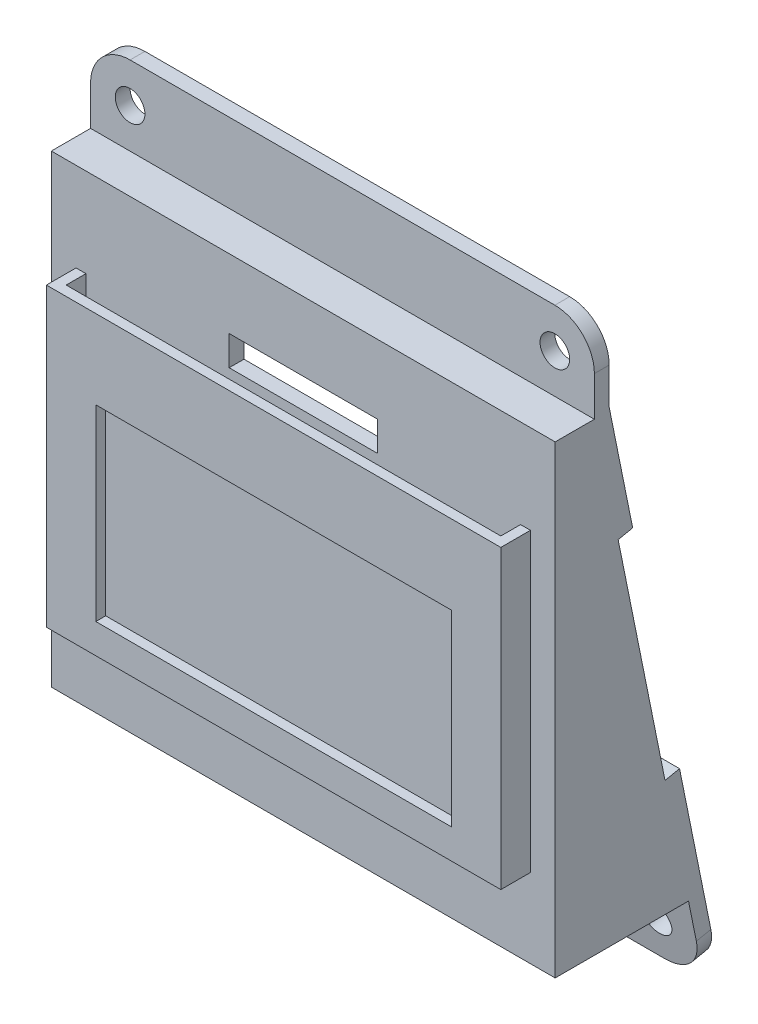
from build123d import *

# Parameters (mm, degrees)
SKETCH_1_W          = 51
SKETCH_1_H          = 47
SKETCH_1_W_2        = 15
SKETCH_1_H_2        = 3
EXTRUDE_1_DEPTH     = 1.5
EXTRUDE_2_DEPTH     = 2
SKETCH_3_W          = 46
SKETCH_3_H          = 30
SKETCH_3_W_2        = 36
SKETCH_3_H_2        = 19
EXTRUDE_3_DEPTH     = 1
SKETCH_4_W          = 51
SKETCH_4_H          = 47
SKETCH_4_W_2        = 48
SKETCH_4_H_2        = 44.5
EXTRUDE_4_DEPTH     = 12
CUT_EXTRUDE_1_DEPTH = 52
SKETCH_6_W          = 51
SKETCH_6_H          = 12
SKETCH_6_R          = 1.5
EXTRUDE_5_DEPTH     = 1.5
SKETCH_7_W          = 1.5
SKETCH_7_H          = 8
EXTRUDE_6_DEPTH     = 51
FILLET_1_R          = 4
CUT_EXTRUDE_2_REACH = 14.585
SKETCH_8_R          = 1.5
CUT_EXTRUDE_3_REACH = 53
SKETCH_9_R          = 4.5


with BuildPart() as part:
    # 草图1 → 凸台-拉伸1 (new body)
    with BuildSketch(Plane.XY):
        with Locations((25.5, 23.5)):
            Rectangle(SKETCH_1_W, SKETCH_1_H)
        with Locations((25.5, 38.5)):
            Rectangle(SKETCH_1_W_2, SKETCH_1_H_2, mode=Mode.SUBTRACT)
    extrude(amount=EXTRUDE_1_DEPTH)

    # 草图2 → 凸台-拉伸2 (add)
    with BuildSketch(Plane.XY.offset(1.5)):
        Polygon((2.5, 8), (48.5, 8), (48.5, 38), (47.5, 38), (47.5, 9), (3.5, 9), (3.5, 38), (2.5, 38), align=None)
    extrude(amount=EXTRUDE_2_DEPTH)

    # 草图3 → 凸台-拉伸3 (add)
    with BuildSketch(Plane.XY.offset(3.5)):
        with Locations((25.5, 23)):
            Rectangle(SKETCH_3_W, SKETCH_3_H)
        with Locations((25.5, 20.5)):
            Rectangle(SKETCH_3_W_2, SKETCH_3_H_2, mode=Mode.SUBTRACT)
    extrude(amount=EXTRUDE_3_DEPTH)

    # 草图4 → 凸台-拉伸4 (add)
    with BuildSketch(Plane(origin=(0, 0, 0), x_dir=(-1, 0, 0), z_dir=(0, 0, -1))):
        with Locations((-25.5, 23.5)):
            Rectangle(SKETCH_4_W, SKETCH_4_H)
        with Locations((-25.5, 23.75)):
            Rectangle(SKETCH_4_W_2, SKETCH_4_H_2, mode=Mode.SUBTRACT)
    extrude(amount=EXTRUDE_4_DEPTH)

    # 草图5 → 切除-拉伸1 (cut, through all)
    with BuildSketch(Plane(origin=(51, 0, 0), x_dir=(0, 0, -1), z_dir=(1, 0, 0))):
        Polygon((2.5, 47), (12, 47), (12, 0), align=None)
    extrude(amount=-CUT_EXTRUDE_1_DEPTH, mode=Mode.SUBTRACT)

    # 草图6 → 凸台-拉伸5 (add)
    with BuildSketch(Plane(origin=(0, 2.330325106, -11.52897684), x_dir=(-1, 0, 0), z_dir=(0, 0.198120998, -0.980177571))):
        with Locations((-25.5, 39.573043325)):
            Rectangle(SKETCH_6_W, SKETCH_6_H)
        with BuildLine():
            Line((-51, 9.62254802), (0, 9.62254802))
            Line((0, 9.62254802), (0, -6.37745198))
            ThreePointArc((0, -6.37745198), (-1.171572875, -9.205879105), (-4, -10.37745198))
            Line((-4, -10.37745198), (-47, -10.37745198))
            ThreePointArc((-47, -10.37745198), (-49.828427125, -9.205879105), (-51, -6.37745198))
            Line((-51, -6.37745198), (-51, 9.62254802))
        make_face()
        with Locations((-47, -6.37745198)):
            Circle(SKETCH_6_R, mode=Mode.SUBTRACT)
        with Locations((-4, -6.37745198)):
            Circle(SKETCH_6_R, mode=Mode.SUBTRACT)
    extrude(amount=EXTRUDE_5_DEPTH)

    # 草图7 → 凸台-拉伸6 (add)
    with BuildSketch(Plane(origin=(51, 0, 0), x_dir=(0, 0, -1), z_dir=(1, 0, 0))):
        with Locations((3.220266356, 51)):
            Rectangle(SKETCH_7_W, SKETCH_7_H)
    extrude(amount=-EXTRUDE_6_DEPTH)

    # 圆角1
    fillet_1_edges = [part.edges().sort_by_distance(p)[0] for p in [
        (51, 55, -3.220266356),
        (0, 55, -3.220266356),
    ]]
    fillet(fillet_1_edges, radius=FILLET_1_R)

    # 草图8 → 切除-拉伸2 (cut, up to next)
    with BuildSketch(Plane.XY.offset(-2.470266356), mode=Mode.PRIVATE) as cut_extrude_2_sk1:
        with Locations((4, 51)):
            Circle(SKETCH_8_R)
    cut_extrude_2_tool1 = extrude(cut_extrude_2_sk1.sketch, amount=-CUT_EXTRUDE_2_REACH, mode=Mode.PRIVATE) & part.part
    add(cut_extrude_2_tool1.solids().sort_by_distance((4, 51, -2.470266))[0], mode=Mode.SUBTRACT)
    # 草图8 → 切除-拉伸2 (cut, up to next)
    with BuildSketch(Plane.XY.offset(-2.470266356), mode=Mode.PRIVATE) as cut_extrude_2_sk2:
        with Locations((47, 51)):
            Circle(SKETCH_8_R)
    cut_extrude_2_tool2 = extrude(cut_extrude_2_sk2.sketch, amount=-CUT_EXTRUDE_2_REACH, mode=Mode.PRIVATE) & part.part
    add(cut_extrude_2_tool2.solids().sort_by_distance((47, 51, -2.470266))[0], mode=Mode.SUBTRACT)

    # 草图9 → 切除-拉伸3 (cut, up to next)
    with BuildSketch(Plane.ZY, mode=Mode.PRIVATE) as cut_extrude_3_sk1:
        with Locations((-4.5, 7)):
            Circle(SKETCH_9_R)
    cut_extrude_3_tool1 = extrude(cut_extrude_3_sk1.sketch, amount=-CUT_EXTRUDE_3_REACH, mode=Mode.PRIVATE) & part.part
    add(cut_extrude_3_tool1.solids().sort_by_distance((0, 7, -4.5))[0], mode=Mode.SUBTRACT)


solid = part.part
